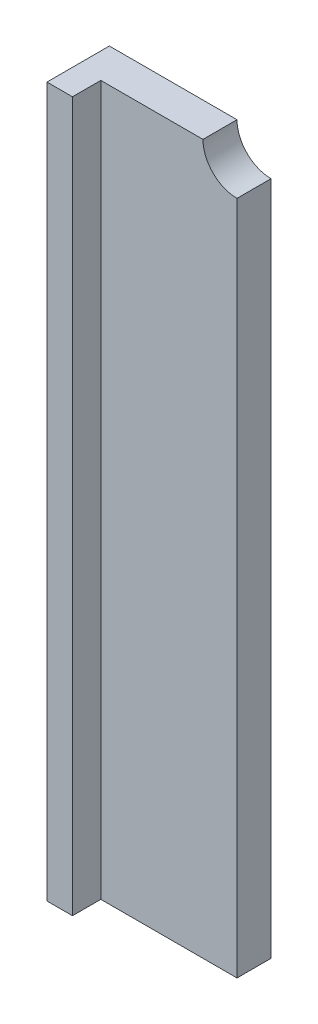
from build123d import *

# Parameters (mm, degrees)
CROQUIS1_W              = 28.5
CROQUIS1_H              = 125
SALIENTE_EXTRUIR1_DEPTH = 6
CROQUIS2_W              = 4.5
CROQUIS2_H              = 125
SALIENTE_EXTRUIR2_DEPTH = 5
CROQUIS3_R              = 6
CORTAR_EXTRUIR1_DEPTH   = 7


with BuildPart() as part:
    # Croquis1 → Saliente-Extruir1 (new body)
    with BuildSketch(Plane.XY):
        with Locations((14.25, 62.5)):
            Rectangle(CROQUIS1_W, CROQUIS1_H)
    extrude(amount=SALIENTE_EXTRUIR1_DEPTH)

    # Croquis2 → Saliente-Extruir2 (add)
    with BuildSketch(Plane.XY.offset(6)):
        with Locations((2.25, 62.5)):
            Rectangle(CROQUIS2_W, CROQUIS2_H)
    extrude(amount=SALIENTE_EXTRUIR2_DEPTH)

    # Croquis3 → Cortar-Extruir1 (cut, through all)
    with BuildSketch(Plane.XY.offset(6)):
        with Locations((28.5, 125)):
            Circle(CROQUIS3_R)
    extrude(amount=-CORTAR_EXTRUIR1_DEPTH, mode=Mode.SUBTRACT)


solid = part.part
